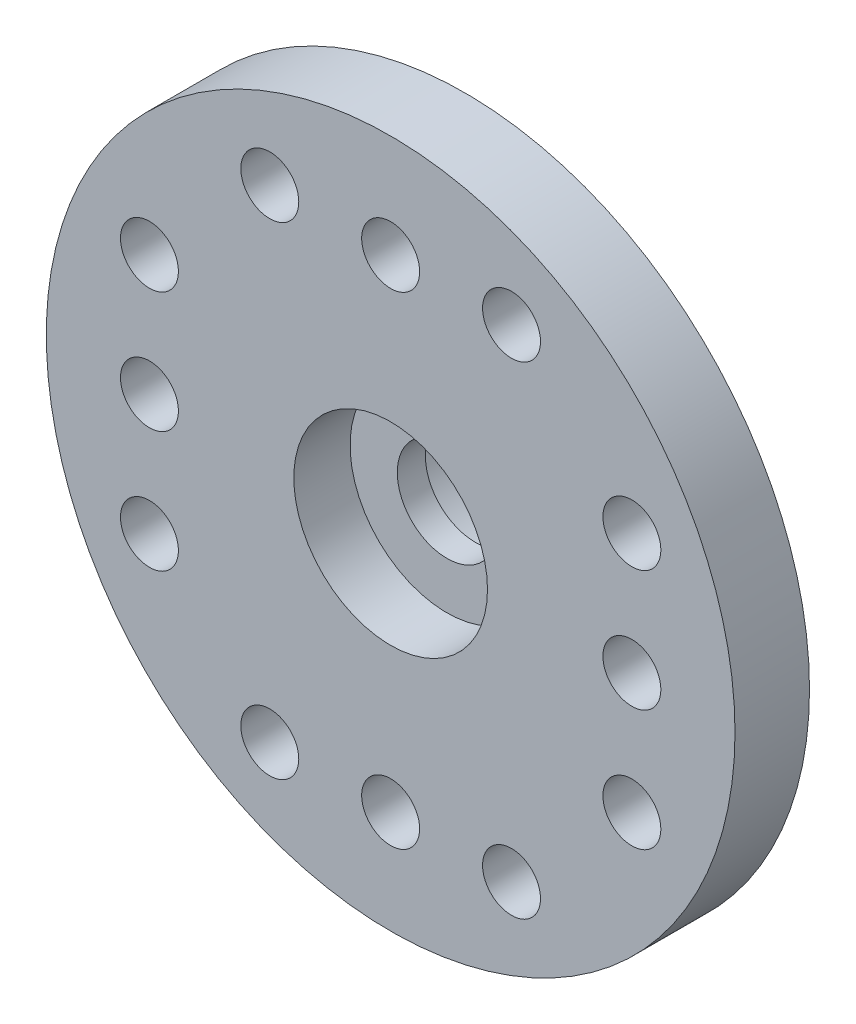
from build123d import *

# Parameters (mm, degrees)
SKETCH1_R           = 10.4
BOSS_EXTRUDE1_DEPTH = 2.25
SKETCH2_R           = 4.4
BOSS_EXTRUDE2_DEPTH = 3.3
SKETCH3_R           = 1.5
SKETCH3_R_2         = 0.875
CUT_EXTRUDE1_DEPTH  = 5.55
SKETCH4_R           = 2.925
CUT_EXTRUDE2_DEPTH  = 1.7
SKETCH5_R           = 2.95
CUT_EXTRUDE3_DEPTH  = 3


with BuildPart() as part:
    # Sketch1 → Boss-Extrude1 (new body)
    with BuildSketch(Plane.XY):
        with Locations((9.62, 10)):
            Circle(SKETCH1_R)
    extrude(amount=BOSS_EXTRUDE1_DEPTH)

    # Sketch2 → Boss-Extrude2 (add)
    with BuildSketch(Plane(origin=(0, 0, 0), x_dir=(-1, 0, 0), z_dir=(0, 0, -1))):
        with Locations((-9.62, 10)):
            Circle(SKETCH2_R)
    extrude(amount=BOSS_EXTRUDE2_DEPTH)

    # Sketch3 → Cut-Extrude1 (cut)
    with BuildSketch(Plane.XY.offset(2.25)):
        with Locations((9.62, 10)):
            Circle(SKETCH3_R)
        with Locations((9.62, 2.715)):
            Circle(SKETCH3_R_2)
        with Locations((5.97, 2.715)):
            Circle(SKETCH3_R_2)
        with Locations((13.27, 2.715)):
            Circle(SKETCH3_R_2)
        with Locations((2.335, 6.35)):
            Circle(SKETCH3_R_2)
        with Locations((2.335, 10)):
            Circle(SKETCH3_R_2)
        with Locations((2.335, 13.65)):
            Circle(SKETCH3_R_2)
        with Locations((5.97, 17.285)):
            Circle(SKETCH3_R_2)
        with Locations((9.62, 17.285)):
            Circle(SKETCH3_R_2)
        with Locations((13.27, 17.285)):
            Circle(SKETCH3_R_2)
        with Locations((16.905, 13.65)):
            Circle(SKETCH3_R_2)
        with Locations((16.905, 10)):
            Circle(SKETCH3_R_2)
        with Locations((16.905, 6.35)):
            Circle(SKETCH3_R_2)
    extrude(amount=-CUT_EXTRUDE1_DEPTH, mode=Mode.SUBTRACT)

    # Sketch4 → Cut-Extrude2 (cut)
    with BuildSketch(Plane.XY.offset(2.25)):
        with Locations((9.62, 10)):
            Circle(SKETCH4_R)
    extrude(amount=-CUT_EXTRUDE2_DEPTH, mode=Mode.SUBTRACT)

    # Sketch5 → Cut-Extrude3 (cut)
    with BuildSketch(Plane(origin=(0, 0, -3.3), x_dir=(-1, 0, 0), z_dir=(0, 0, -1))):
        with Locations((-9.62, 10)):
            Circle(SKETCH5_R)
    extrude(amount=-CUT_EXTRUDE3_DEPTH, mode=Mode.SUBTRACT)


solid = part.part
